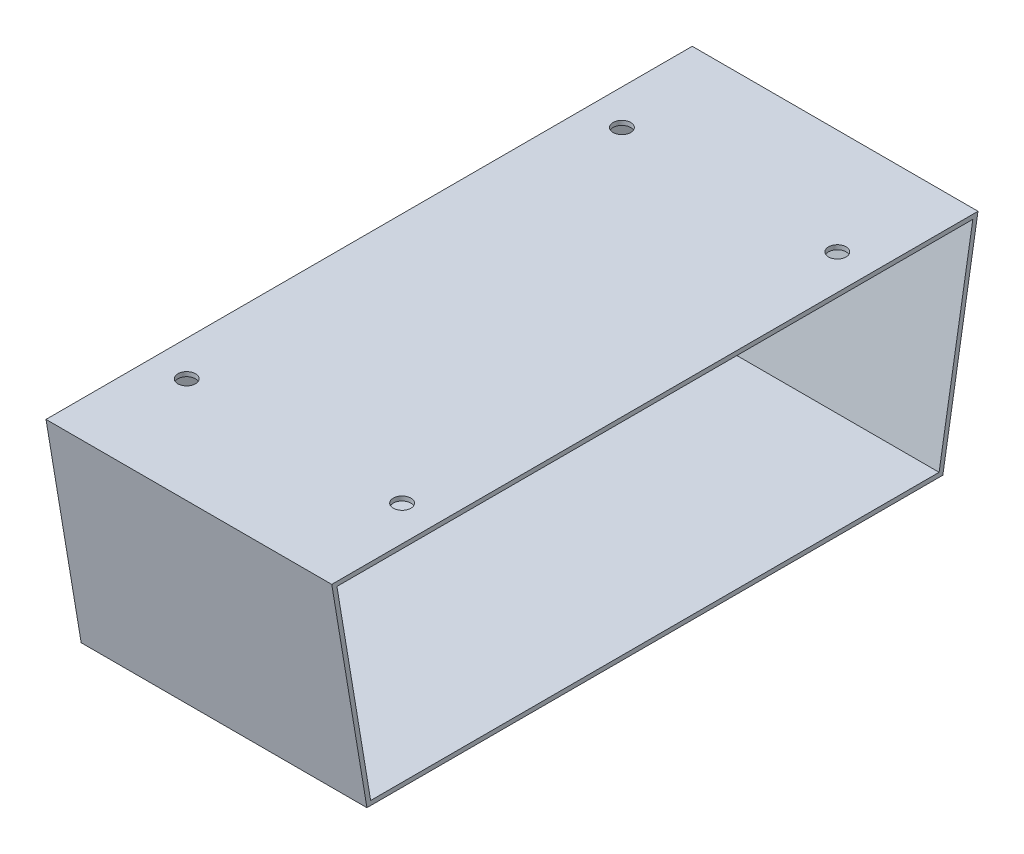
from build123d import *

# Parameters (mm, degrees)
BOSS_EXTRUDE1_DEPTH = 3.175
BOSS_EXTRUDE2_DEPTH = 203.2
SKETCH3_R           = 6.35
CUT_EXTRUDE1_DEPTH  = 3.175


with BuildPart() as part:
    # Sketch1 → Boss-Extrude1 (new body)
    with BuildSketch(Plane(origin=(0, 0, 0), x_dir=(0, 0, -1), z_dir=(1, 0, 0))):
        Polygon((-358.316862416, 16.748657718), (-383.716862416, 169.148657718), (83.008137584, 169.148657718), (57.608137584, 16.748657718), align=None)
    extrude(amount=BOSS_EXTRUDE1_DEPTH)

    # Sketch2 → Boss-Extrude2 (add)
    with BuildSketch(Plane(origin=(3.175, 0, 0), x_dir=(0, 0, -1), z_dir=(1, 0, 0))):
        Polygon((-383.716862416, 169.148657718), (-358.316862416, 16.748657718), (57.608137584, 16.748657718), (83.008137584, 169.148657718), align=None)
        Polygon((54.918509078, 19.923657718), (79.260175745, 165.973657718), (-379.968900577, 165.973657718), (-355.62723391, 19.923657718), align=None, mode=Mode.SUBTRACT)
    extrude(amount=BOSS_EXTRUDE2_DEPTH)

    # Sketch3 → Cut-Extrude1 (cut)
    with BuildSketch(Plane(origin=(0, 169.148657718, 0), x_dir=(1, 0, 0), z_dir=(0, 1, 0))):
        with Locations((180.975, 6.808137584)):
            Circle(SKETCH3_R)
        with Locations((25.4, 6.808137584)):
            Circle(SKETCH3_R)
        with Locations((25.4, -307.516862416)):
            Circle(SKETCH3_R)
        with Locations((180.975, -307.516862416)):
            Circle(SKETCH3_R)
    extrude(amount=-CUT_EXTRUDE1_DEPTH, mode=Mode.SUBTRACT)


solid = part.part
